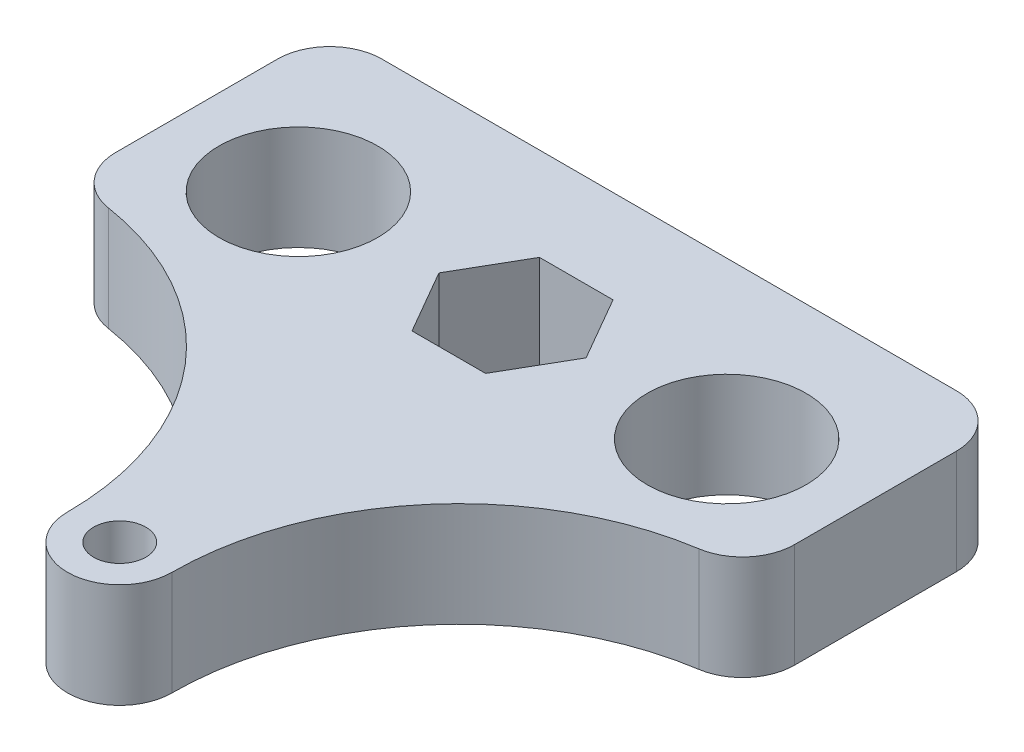
from build123d import *

# Parameters (mm, degrees)
SKETCH1_R           = 7.6
SKETCH1_R_2         = 2.5
BOSS_EXTRUDE1_DEPTH = 10


with BuildPart() as part:
    # Sketch1 → Boss-Extrude1 (new body)
    with BuildSketch(Plane(origin=(0, 0, 0), x_dir=(1, 0, 0), z_dir=(0, 1, 0))):
        with BuildLine():
            Line((-27.5, 25.1), (27.5, 25.1))
            ThreePointArc((27.5, 25.1), (31.035533906, 23.635533906), (32.5, 20.1))
            Line((32.5, 20.1), (32.5, 4.613081447))
            ThreePointArc((32.5, 4.613081447), (31.297772627, 1.360863269), (28.269230769, -0.327392622))
            ThreePointArc((28.269230769, -0.327392622), (11.612250554, -9.612800021), (5, -27.5))
            ThreePointArc((5, -27.5), (0, -32.5), (-5, -27.5))
            ThreePointArc((-5, -27.5), (-11.612250554, -9.612800021), (-28.269230769, -0.327392622))
            ThreePointArc((-28.269230769, -0.327392622), (-31.297772627, 1.360863269), (-32.5, 4.613081447))
            Line((-32.5, 4.613081447), (-32.5, 20.1))
            ThreePointArc((-32.5, 20.1), (-31.035533906, 23.635533906), (-27.5, 25.1))
        make_face()
        with Locations(Location((-20.5, 10.1, 0), (0, 0, 270))):  # turned: the seam where the file's is
            Circle(SKETCH1_R, mode=Mode.SUBTRACT)
        with Locations(Location((20.5, 10.1, 0), (0, 0, 270))):  # turned: the seam where the file's is
            Circle(SKETCH1_R, mode=Mode.SUBTRACT)
        with Locations(Location((0, -27.5, 0), (0, 0, 270))):  # turned: the seam where the file's is
            Circle(SKETCH1_R_2, mode=Mode.SUBTRACT)
        Polygon((7.043673284, 10.1), (3.521836642, 16.2), (-3.521836642, 16.2), (-7.043673284, 10.1), (-3.521836642, 4), (3.521836642, 4), align=None, mode=Mode.SUBTRACT)
    extrude(amount=BOSS_EXTRUDE1_DEPTH)


solid = part.part
